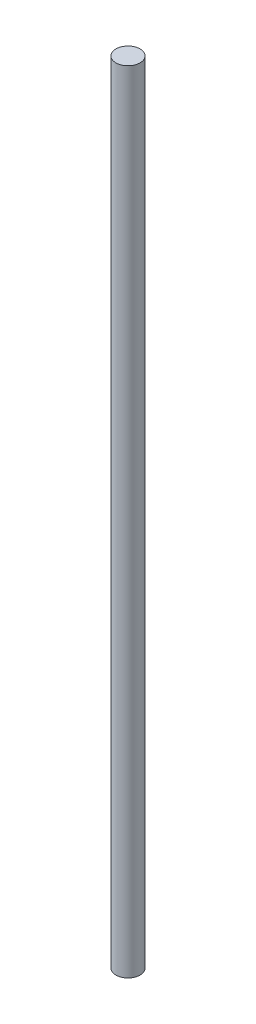
from build123d import *

# Parameters (mm, degrees)
SKETCH1_R           = 3
BOSS_EXTRUDE1_DEPTH = 196


with BuildPart() as part:
    # Sketch1 → Boss-Extrude1 (new body)
    with BuildSketch(Plane(origin=(0, 0, 0), x_dir=(1, 0, 0), z_dir=(0, 1, 0))):
        Circle(SKETCH1_R)
    extrude(amount=BOSS_EXTRUDE1_DEPTH)


solid = part.part
